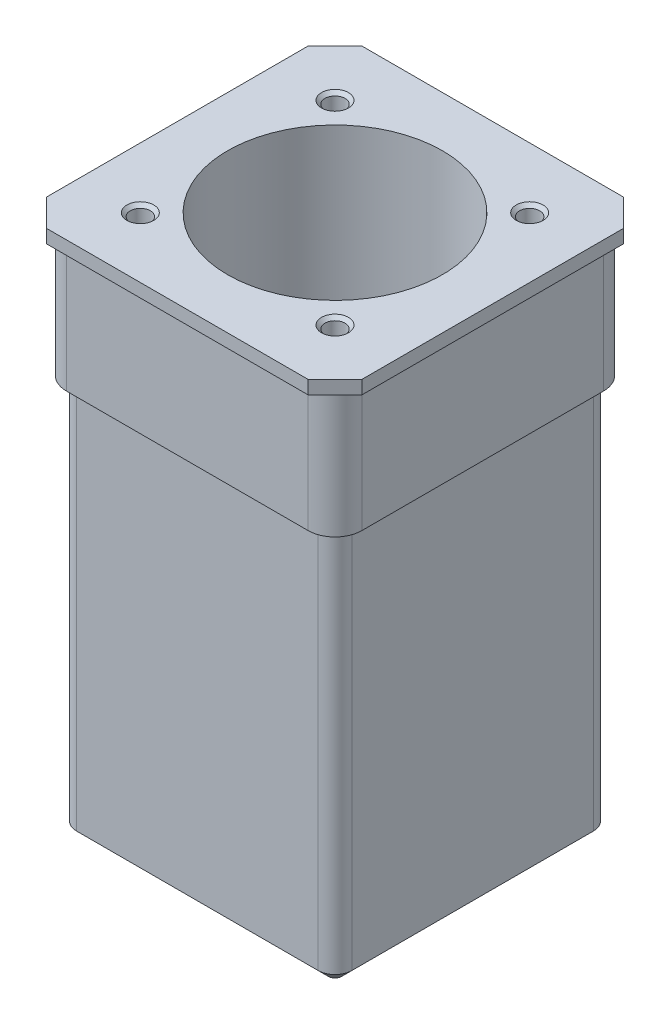
from build123d import *

# Parameters (mm, degrees)
SKETCH_1_W                    = 41
SKETCH_1_H                    = 41
EXTRUDE_1_DEPTH               = 59
SKETCH_2_W                    = 44
SKETCH_2_H                    = 44
EXTRUDE_2_DEPTH               = 19
SKETCH_3_W                    = 47
SKETCH_3_H                    = 47
EXTRUDE_3_DEPTH               = 2
FILLET_1_R                    = 2.5
FILLET_2_R                    = 4
CHAMFER_1_SIZE                = 1.5
CHAMFER_2_SIZE                = 4
SKETCH_4_R                    = 16
CUT_EXTRUDE_4_DEPTH           = 81
M4X0_71_D                     = 3
M4X0_71_DEPTH                 = 14
M4X0_71_CSINK_D               = 4
M4X0_71_CSINK_ANGLE           = 90
M4X0_71_TIP                   = 0.901290929
M4X0_71_ON_FACE_2_D           = 3
M4X0_71_ON_FACE_2_DEPTH       = 14
M4X0_71_ON_FACE_2_CSINK_D     = 4
M4X0_71_ON_FACE_2_CSINK_ANGLE = 90
M4X0_71_ON_FACE_2_TIP         = 0.901290929


with BuildPart() as part:
    # Эскиз1 → Вытянуть1 (new body)
    with BuildSketch(Plane(origin=(0, 0, 0), x_dir=(1, 0, 0), z_dir=(0, 1, 0))):
        Rectangle(SKETCH_1_W, SKETCH_1_H)
    extrude(amount=EXTRUDE_1_DEPTH)

    # Эскиз2 → Вытянуть2 (add)
    with BuildSketch(Plane(origin=(0, 59, 0), x_dir=(1, 0, 0), z_dir=(0, 1, 0))):
        Rectangle(SKETCH_2_W, SKETCH_2_H)
    extrude(amount=EXTRUDE_2_DEPTH)

    # Эскиз3 → Вытянуть3 (add)
    with BuildSketch(Plane(origin=(0, 78, 0), x_dir=(1, 0, 0), z_dir=(0, 1, 0))):
        Rectangle(SKETCH_3_W, SKETCH_3_H)
    extrude(amount=EXTRUDE_3_DEPTH)

    # Скругление1
    fillet_1_edges = [part.edges().sort_by_distance(p)[0] for p in [
        (20.5, 29.5, 20.5),
        (-20.5, 29.5, 20.5),
        (-20.5, 29.5, -20.5),
        (20.5, 29.5, -20.5),
    ]]
    fillet(fillet_1_edges, radius=FILLET_1_R)

    # Скругление2
    fillet_2_edges = [part.edges().sort_by_distance(p)[0] for p in [
        (22, 68.5, 22),
        (22, 68.5, -22),
        (-22, 68.5, -22),
        (-22, 68.5, 22),
    ]]
    fillet(fillet_2_edges, radius=FILLET_2_R)

    # Фаска1
    chamfer_1_edges = [part.edges().sort_by_distance(p)[0] for p in [
        (-20.5, 0, 0),
        (20.5, 0, 0),
        (0, 0, 20.5),
        (0, 0, -20.5),
        (19.767766953, 0, 19.767766953),
        (19.767766953, 0, -19.767766953),
        (-19.767766953, 0, 19.767766953),
        (-19.767766953, 0, -19.767766953),
    ]]
    chamfer(chamfer_1_edges, length=CHAMFER_1_SIZE)

    # Фаска2
    chamfer_2_edges = [part.edges().sort_by_distance(p)[0] for p in [
        (23.5, 79, 23.5),
        (23.5, 79, -23.5),
        (-23.5, 79, -23.5),
        (-23.5, 79, 23.5),
    ]]
    chamfer(chamfer_2_edges, length=CHAMFER_2_SIZE)

    # Эскиз4 → Вытянуть4 (cut, through all)
    with BuildSketch(Plane(origin=(0, 80, 0), x_dir=(1, 0, 0), z_dir=(0, 1, 0))):
        Circle(SKETCH_4_R)
    extrude(amount=-CUT_EXTRUDE_4_DEPTH, mode=Mode.SUBTRACT)

    # Отверстие обработанное метчиком M4x0.71
    with Locations(Plane(origin=(-14.495689014, 0, 14.495689014), x_dir=(0, 0, -1), z_dir=(0, -1, 0))):
        with Locations((0, 0), (28.991378028, 0), (28.991378028, 28.991378028), (0, 28.991378028)):
            CounterSinkHole(M4X0_71_D / 2, M4X0_71_CSINK_D / 2, depth=M4X0_71_DEPTH, counter_sink_angle=M4X0_71_CSINK_ANGLE)
            with Locations((0, 0, -(M4X0_71_DEPTH + M4X0_71_TIP / 2))):  # 118° drill point
                Cone(0, M4X0_71_D / 2, M4X0_71_TIP, mode=Mode.SUBTRACT)

    # Отверстие обработанное метчиком M4x0.71 on face 2
    with Locations(Plane(origin=(-14.495689014, 80, 14.495689014), x_dir=(0, 0, 1), z_dir=(0, 1, 0))):
        with Locations((0, 0), (0, 28.991378028), (-28.991378028, 28.991378028), (-28.991378028, 0)):
            CounterSinkHole(M4X0_71_ON_FACE_2_D / 2, M4X0_71_ON_FACE_2_CSINK_D / 2, depth=M4X0_71_ON_FACE_2_DEPTH, counter_sink_angle=M4X0_71_ON_FACE_2_CSINK_ANGLE)
            with Locations((0, 0, -(M4X0_71_ON_FACE_2_DEPTH + M4X0_71_ON_FACE_2_TIP / 2))):  # 118° drill point
                Cone(0, M4X0_71_ON_FACE_2_D / 2, M4X0_71_ON_FACE_2_TIP, mode=Mode.SUBTRACT)


solid = part.part
